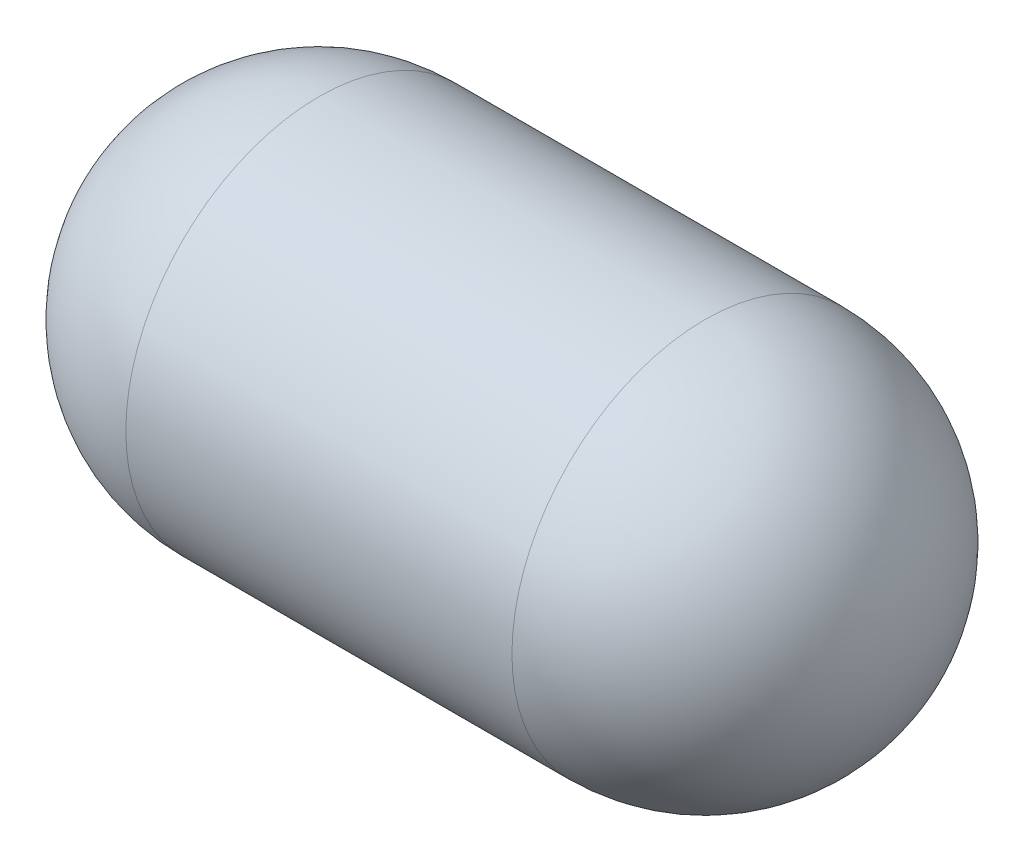
from build123d import *

# Parameters (mm, degrees)
SKETCH1_R           = 3.175
BOSS_EXTRUDE1_DEPTH = 12.7
FILLET1_R           = 3.175


with BuildPart() as part:
    # Sketch1 → Boss-Extrude1 (new body)
    with BuildSketch(Plane(origin=(0, 0, 0), x_dir=(0, 0, -1), z_dir=(1, 0, 0))):
        Circle(SKETCH1_R)
    extrude(amount=BOSS_EXTRUDE1_DEPTH)

    # Fillet1
    fillet1_edges = [part.edges().sort_by_distance(p)[0] for p in [
        (0, 0, 3.175),
        (12.7, 0, 3.175),
    ]]
    fillet(fillet1_edges, radius=FILLET1_R)


solid = part.part
